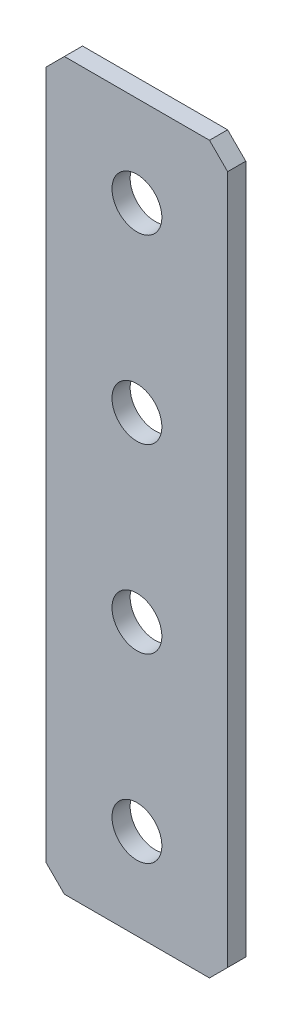
from build123d import *

# Parameters (mm, degrees)
SKETCH_1_W        = 20
SKETCH_1_H        = 80
EXTRUDE_1_DEPTH   = 2
CHAMFER_1_SIZE    = 2
HOLE_WIZARD_M51_D = 5.5


with BuildPart() as part:
    # Эскиз1 → Бобышка-Вытянуть1 (new body)
    with BuildSketch(Plane.XY):
        Rectangle(SKETCH_1_W, SKETCH_1_H)
    extrude(amount=EXTRUDE_1_DEPTH)

    # Фаска1
    chamfer_1_edges = [part.edges().sort_by_distance(p)[0] for p in [
        (10, -40, 1),
        (-10, -40, 1),
        (-10, 40, 1),
        (10, 40, 1),
    ]]
    chamfer(chamfer_1_edges, length=CHAMFER_1_SIZE)

    # Отверстие с зазором M51 (through all)
    with Locations(Plane.XY.offset(2)):
        with Locations((0, -30), (0, 30), (0, 10), (0, -10)):
            Hole(HOLE_WIZARD_M51_D / 2)


solid = part.part
